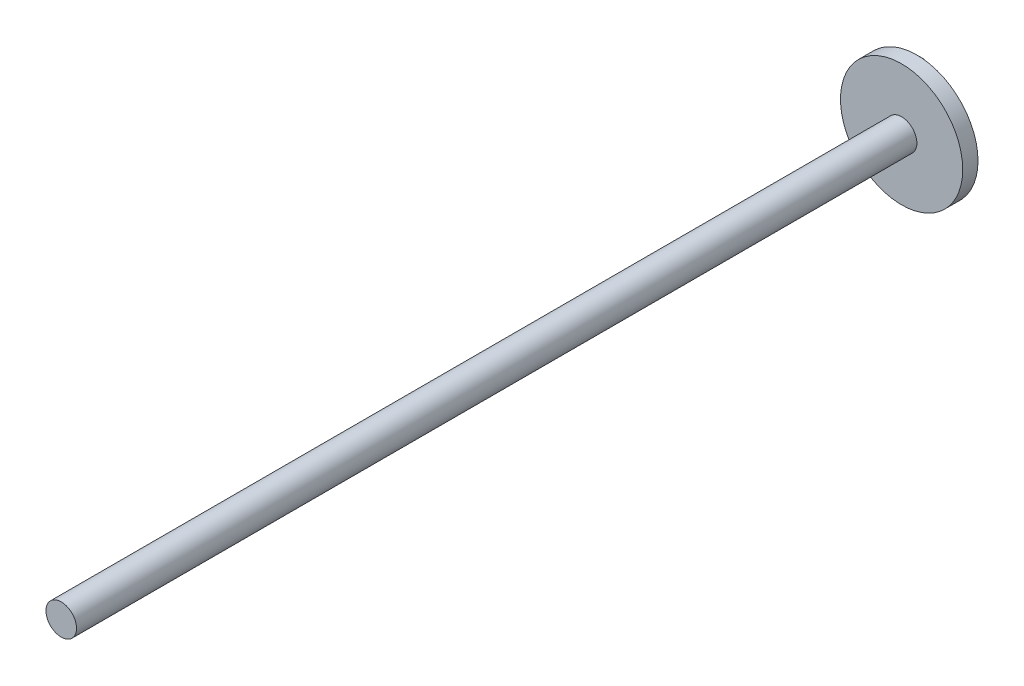
from build123d import *

# Parameters (mm, degrees)
SKETCH1_R           = 40
BOSS_EXTRUDE1_DEPTH = 10
SKETCH2_R           = 10
BOSS_EXTRUDE2_DEPTH = 550
SKETCH3_R           = 10
BOSS_EXTRUDE3_DEPTH = 30


with BuildPart() as part:
    # Sketch1 → Boss-Extrude1 (new body)
    with BuildSketch(Plane.XY):
        Circle(SKETCH1_R)
    extrude(amount=BOSS_EXTRUDE1_DEPTH)

    # Sketch2 → Boss-Extrude2 (add)
    with BuildSketch(Plane.XY.offset(10)):
        Circle(SKETCH2_R)
    extrude(amount=BOSS_EXTRUDE2_DEPTH)

    # Sketch3 → Boss-Extrude3 (add)
    with BuildSketch(Plane(origin=(0, 0, 0), x_dir=(-1, 0, 0), z_dir=(0, 0, -1))):
        with Locations((26.998561916, 0)):
            Circle(SKETCH3_R)
    extrude(amount=BOSS_EXTRUDE3_DEPTH)


solid = part.part
